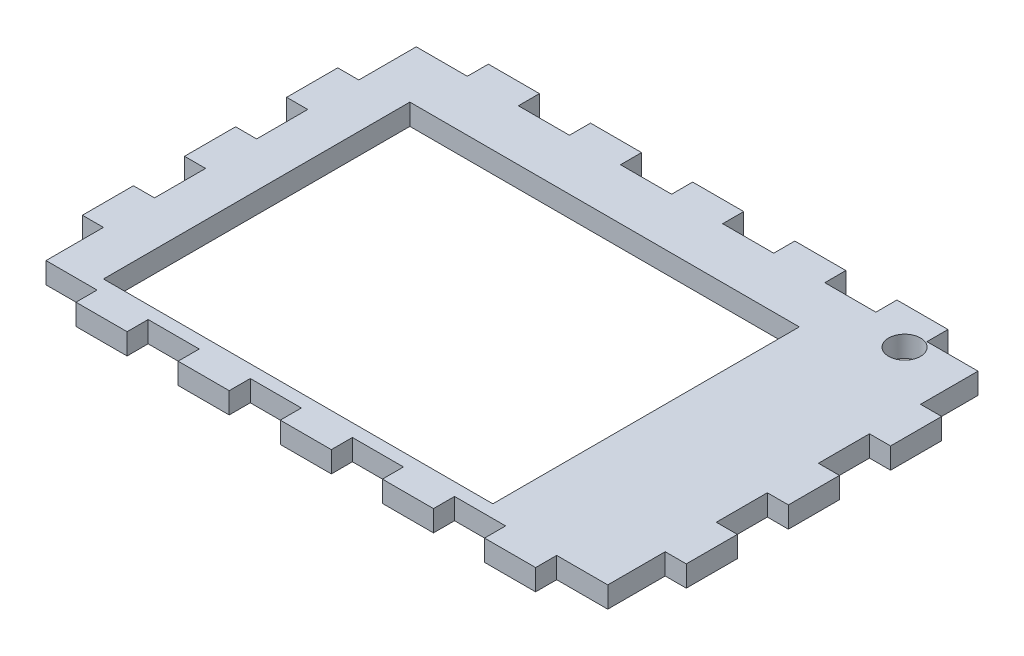
from build123d import *

# Parameters (mm, degrees)
ESQUISSE4_W                    = 88
ESQUISSE4_H                    = 58
BOSS_EXTRU_3_DEPTH             = 3.3
ESQUISSE5_W                    = 8
ESQUISSE5_H                    = 3.3
BOSS_EXTRU_6_DEPTH             = 3.3
R_P_TITION_LIN_AIRE2_COUNT     = 3
R_P_TITION_LIN_AIRE2_PITCH     = 16
R_P_TITION_LIN_AIRE2_COL_COUNT = 3
R_P_TITION_LIN_AIRE2_COL_PITCH = 16
SYM_TRIE1_COPY_1_SKETCH_W      = 8
SYM_TRIE1_COPY_1_SKETCH_H      = 3.3
SYM_TRIE1_COPY_1_DEPTH         = 3.3
SYM_TRIE1_COPY_2_SKETCH_W      = 8
SYM_TRIE1_COPY_2_SKETCH_H      = 3.3
SYM_TRIE1_COPY_2_DEPTH         = 3.3
SYM_TRIE1_COPY_3_SKETCH_W      = 8
SYM_TRIE1_COPY_3_SKETCH_H      = 3.3
SYM_TRIE1_COPY_3_DEPTH         = 3.3
SYM_TRIE1_COPY_4_SKETCH_W      = 8
SYM_TRIE1_COPY_4_SKETCH_H      = 3.3
SYM_TRIE1_COPY_4_DEPTH         = 3.3
ESQUISSE6_W                    = 3.3
ESQUISSE6_H                    = 8
BOSS_EXTRU_7_DEPTH             = 3.3
R_P_TITION_LIN_AIRE3_COUNT     = 2
R_P_TITION_LIN_AIRE3_PITCH     = 16
R_P_TITION_LIN_AIRE3_COL_COUNT = 2
R_P_TITION_LIN_AIRE3_COL_PITCH = 16
SYM_TRIE2_COPY_1_SKETCH_W      = 3.3
SYM_TRIE2_COPY_1_SKETCH_H      = 8
SYM_TRIE2_COPY_1_DEPTH         = 3.3
SYM_TRIE2_COPY_2_SKETCH_W      = 3.3
SYM_TRIE2_COPY_2_SKETCH_H      = 8
SYM_TRIE2_COPY_2_DEPTH         = 3.3
ESQUISSE7_R                    = 2.5
ESQUISSE7_W                    = 61
ESQUISSE7_H                    = 48
ENL_V_MAT_EXTRU_1_DEPTH        = 1
ENL_V_MAT_EXTRU_1_DEPTH_BACK   = 4.3


with BuildPart() as part:
    # Esquisse4 → Boss.-Extru.3 (new body)
    with BuildSketch(Plane(origin=(0, 0, 0), x_dir=(1, 0, 0), z_dir=(0, 1, 0))):
        Rectangle(ESQUISSE4_W, ESQUISSE4_H)
    extrude(amount=BOSS_EXTRU_3_DEPTH)

    # Esquisse5 → Boss.-Extru.6 (add)
    with BuildSketch(Plane.XZ):
        with Locations((0, 30.65)):
            Rectangle(ESQUISSE5_W, ESQUISSE5_H)
    boss_extru_6 = extrude(amount=-BOSS_EXTRU_6_DEPTH)

    # Répétition linéaire2: Boss.-Extru.6 ×3
    with Locations(*[(-i * R_P_TITION_LIN_AIRE2_PITCH, 0, 0) for i in range(1, R_P_TITION_LIN_AIRE2_COUNT)]):
        add(boss_extru_6)

    # Répétition linéaire2 col: Boss.-Extru.6 ×3
    with Locations(*[(i * R_P_TITION_LIN_AIRE2_COL_PITCH, 0, 0) for i in range(1, R_P_TITION_LIN_AIRE2_COL_COUNT)]):
        add(boss_extru_6)

    # Symétrie1: Boss.-Extru.6 across plane
    add(boss_extru_6.mirror(Plane.XY))

    # Symétrie1 copy 1 sketch → Symétrie1 copy 1 (add)
    with BuildSketch(Plane(origin=(-16, 0, 0), x_dir=(1, 0, 0), z_dir=(0, -1, 0))):
        with Locations((0, -30.65)):
            Rectangle(SYM_TRIE1_COPY_1_SKETCH_W, SYM_TRIE1_COPY_1_SKETCH_H)
    extrude(amount=-SYM_TRIE1_COPY_1_DEPTH)

    # Symétrie1 copy 2 sketch → Symétrie1 copy 2 (add)
    with BuildSketch(Plane(origin=(-32, 0, 0), x_dir=(1, 0, 0), z_dir=(0, -1, 0))):
        with Locations((0, -30.65)):
            Rectangle(SYM_TRIE1_COPY_2_SKETCH_W, SYM_TRIE1_COPY_2_SKETCH_H)
    extrude(amount=-SYM_TRIE1_COPY_2_DEPTH)

    # Symétrie1 copy 3 sketch → Symétrie1 copy 3 (add)
    with BuildSketch(Plane(origin=(16, 0, 0), x_dir=(1, 0, 0), z_dir=(0, -1, 0))):
        with Locations((0, -30.65)):
            Rectangle(SYM_TRIE1_COPY_3_SKETCH_W, SYM_TRIE1_COPY_3_SKETCH_H)
    extrude(amount=-SYM_TRIE1_COPY_3_DEPTH)

    # Symétrie1 copy 4 sketch → Symétrie1 copy 4 (add)
    with BuildSketch(Plane(origin=(32, 0, 0), x_dir=(1, 0, 0), z_dir=(0, -1, 0))):
        with Locations((0, -30.65)):
            Rectangle(SYM_TRIE1_COPY_4_SKETCH_W, SYM_TRIE1_COPY_4_SKETCH_H)
    extrude(amount=-SYM_TRIE1_COPY_4_DEPTH)

    # Esquisse6 → Boss.-Extru.7 (add)
    with BuildSketch(Plane.XZ):
        with Locations((-45.65, 0)):
            Rectangle(ESQUISSE6_W, ESQUISSE6_H)
    boss_extru_7 = extrude(amount=-BOSS_EXTRU_7_DEPTH)

    # Répétition linéaire3: Boss.-Extru.7 ×2
    with Locations(*[(0, 0, i * R_P_TITION_LIN_AIRE3_PITCH) for i in range(1, R_P_TITION_LIN_AIRE3_COUNT)]):
        add(boss_extru_7)

    # Répétition linéaire3 col: Boss.-Extru.7 ×2
    with Locations(*[(0, 0, -i * R_P_TITION_LIN_AIRE3_COL_PITCH) for i in range(1, R_P_TITION_LIN_AIRE3_COL_COUNT)]):
        add(boss_extru_7)

    # Symétrie2: Boss.-Extru.7 across plane
    add(boss_extru_7.mirror(Plane(origin=(0, 0, 0), x_dir=(0, 0, 1), z_dir=(1, 0, 0))))

    # Symétrie2 copy 1 sketch → Symétrie2 copy 1 (add)
    with BuildSketch(Plane(origin=(0, 0, 16), x_dir=(-1, 0, 0), z_dir=(0, -1, 0))):
        with Locations((-45.65, 0)):
            Rectangle(SYM_TRIE2_COPY_1_SKETCH_W, SYM_TRIE2_COPY_1_SKETCH_H)
    extrude(amount=-SYM_TRIE2_COPY_1_DEPTH)

    # Symétrie2 copy 2 sketch → Symétrie2 copy 2 (add)
    with BuildSketch(Plane(origin=(0, 0, -16), x_dir=(-1, 0, 0), z_dir=(0, -1, 0))):
        with Locations((-45.65, 0)):
            Rectangle(SYM_TRIE2_COPY_2_SKETCH_W, SYM_TRIE2_COPY_2_SKETCH_H)
    extrude(amount=-SYM_TRIE2_COPY_2_DEPTH)

    # Esquisse7 → Enlèv. mat.-Extru.1 (cut, two sides)
    with BuildSketch(Plane.XZ) as enl_v_mat_extru_1_sk:
        with Locations((35, -26.5)):
            Circle(ESQUISSE7_R)
        with Locations((-6.5, 3)):
            Rectangle(ESQUISSE7_W, ESQUISSE7_H)
    extrude(amount=ENL_V_MAT_EXTRU_1_DEPTH, mode=Mode.SUBTRACT)
    extrude(enl_v_mat_extru_1_sk.sketch, amount=-ENL_V_MAT_EXTRU_1_DEPTH_BACK, mode=Mode.SUBTRACT)


solid = part.part
